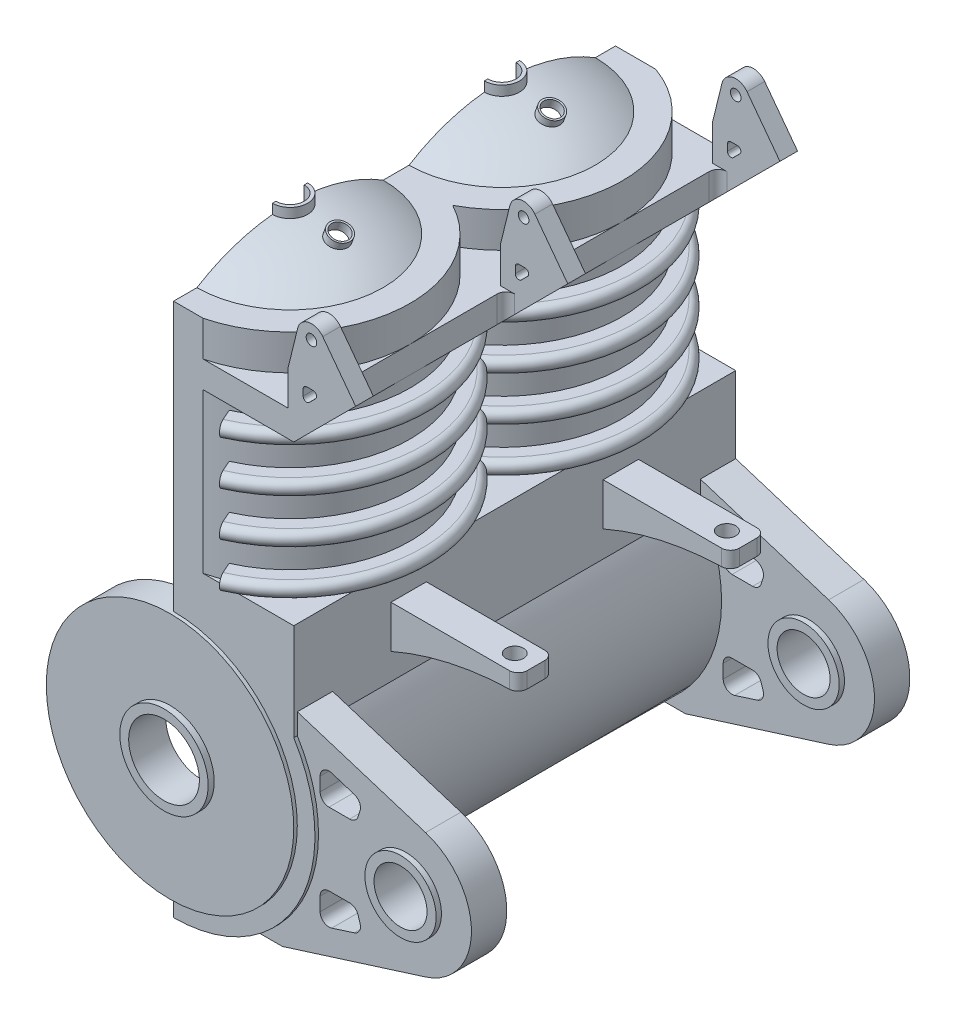
from build123d import *

# Parameters (mm, degrees)
BOSS_EXTRUDE1_DEPTH  = 25
SKETCH7_R            = 5
CUT_EXTRUDE1_DEPTH   = 20
SKETCH8_R            = 7
CUT_EXTRUDE2_DEPTH   = 39.525835487
CUT_EXTRUDE3_DEPTH   = 9
REVOLVE1_ANGLE       = 156
LPATTERN1_COUNT      = 2
LPATTERN1_PITCH      = 12
SKETCH13_R           = 5.038621202
CUT_EXTRUDE4_DEPTH   = 15
BOSS_EXTRUDE2_START  = -1
SKETCH14_R           = 7
SKETCH14_R_2         = 2.5
BOSS_EXTRUDE2_DEPTH  = 1.5
LPATTERN3_COUNT      = 3
LPATTERN3_PITCH      = 12
BOSS_EXTRUDE4_START  = 0.2
SKETCH15_R           = 7
BOSS_EXTRUDE4_DEPTH  = 0.2
BOSS_EXTRUDE5_START  = -1.6
SKETCH16_R           = 2.5
SKETCH16_R_2         = 2
BOSS_EXTRUDE5_DEPTH  = 2.1
LPATTERN4_COUNT      = 3
LPATTERN4_PITCH      = 12.22
BOSS_EXTRUDE6_START  = 2
BOSS_EXTRUDE6_DEPTH  = 2
SKETCH22_R           = 2
CUT_EXTRUDE5_DEPTH   = 42.077109336
SKETCH23_R           = 2.015
BOSS_EXTRUDE7_DEPTH  = 2
LPATTERN5_COUNT      = 2
LPATTERN5_PITCH      = 22.8
BOSS_EXTRUDE8_START  = 0.3
SKETCH25_R           = 2.015
SKETCH25_R_2         = 1.5
BOSS_EXTRUDE8_DEPTH  = 2.6
LPATTERN6_COUNT      = 2
LPATTERN6_PITCH      = 22.8
CUT_EXTRUDE6_DEPTH   = 43.954277827
REVOLVE3_ANGLE       = 180
LPATTERN7_COUNT      = 2
LPATTERN7_PITCH      = 12
SKETCH32_R           = 0.995
CUT_EXTRUDE7_DEPTH   = 10.3
BOSS_EXTRUDE9_START  = 1.2
BOSS_EXTRUDE9_DEPTH  = 0.8
SKETCH35_R           = 0.6
CUT_EXTRUDE8_DEPTH   = 10.8
SKETCH36_R           = 0.3
BOSS_EXTRUDE10_DEPTH = 1
LPATTERN8_COUNT      = 3
LPATTERN8_PITCH      = 12
FILLET2_R            = 0.5
BOSS_EXTRUDE11_START = -5.5
BOSS_EXTRUDE11_DEPTH = 2
LPATTERN9_COUNT      = 2
LPATTERN9_PITCH      = 12
SKETCH38_R           = 0.5
CUT_EXTRUDE9_DEPTH   = 2
FILLET4_R            = 0.5
SKETCH39_W           = 5.995424261
SKETCH39_H           = 2.838070656
CUT_EXTRUDE10_DEPTH  = 45.38321737
SKETCH40_R           = 0.3
BOSS_EXTRUDE12_DEPTH = 1
LPATTERN10_COUNT     = 3
LPATTERN10_PITCH     = 12
EXTRUDE_THIN1_START  = 1.9
SKETCH35_2_R         = 0.6
SKETCH35_2_R_2       = 0.5
EXTRUDE_THIN1_DEPTH  = 0.5


with BuildPart() as part:
    # Sketch2 → Boss-Extrude1 (new body)
    with BuildSketch(Plane.XY):
        with BuildLine():
            Line((0, 28.2), (0, 0))
            ThreePointArc((0, 0), (6.989781542, 4.108605135), (6.8, 12.214261501))
            Line((6.8, 12.214261501), (6.8, 28.2))
            Line((6.8, 28.2), (0, 28.2))
        make_face()
    extrude(amount=BOSS_EXTRUDE1_DEPTH)

    # Sketch7 → Cut-Extrude1 (cut)
    with BuildSketch(Plane(origin=(0, 28.2, 0), x_dir=(1, 0, 0), z_dir=(0, 1, 0))):
        with Locations((0, -6.41)):
            Circle(SKETCH7_R)
        with Locations((0, -18.41)):
            Circle(SKETCH7_R)
    extrude(amount=-CUT_EXTRUDE1_DEPTH, mode=Mode.SUBTRACT)

    # Sketch8 → Cut-Extrude2 (cut, through all)
    with BuildSketch(Plane.XY.offset(25)):
        with Locations((0, 8)):
            Circle(SKETCH8_R)
    extrude(amount=-CUT_EXTRUDE2_DEPTH, mode=Mode.SUBTRACT)

    # Sketch10 → Cut-Extrude3 (cut)
    with BuildSketch(Plane(origin=(0, 26.7, 0), x_dir=(1, 0, 0), z_dir=(0, 1, 0))):
        with BuildLine():
            Line((0, 0.39), (7.457375811, 0.39))
            Line((7.457375811, 0.39), (7.457375811, -25.21))
            Line((7.457375811, -25.21), (0, -25.21))
            ThreePointArc((0, -25.21), (6.596969001, -20.05924225), (3.2, -12.41))
            ThreePointArc((3.2, -12.41), (6.596969001, -4.76075775), (0, 0.39))
        make_face()
    extrude(amount=-CUT_EXTRUDE3_DEPTH, mode=Mode.SUBTRACT)

    # Sketch12 → Revolve1 (revolve)
    with BuildSketch(Plane.ZY):
        with BuildLine():
            Line((0.68, 17.35), (0.68, 27.35))
            Line((0.68, 27.35), (0.175, 27.35))
            Line((0.175, 27.35), (0.175, 26.05))
            Line((0.175, 26.05), (-1.07, 26.05))
            ThreePointArc((-1.07, 26.05), (-1.47, 25.65), (-1.07, 25.25))
            Line((-1.07, 25.25), (0.175, 25.25))
            Line((0.175, 25.25), (0.175, 23.55))
            Line((0.175, 23.55), (-1.07, 23.55))
            ThreePointArc((-1.07, 23.55), (-1.47, 23.15), (-1.07, 22.75))
            Line((-1.07, 22.75), (0.175, 22.75))
            Line((0.175, 22.75), (0.175, 21.05))
            Line((0.175, 21.05), (-1.07, 21.05))
            ThreePointArc((-1.07, 21.05), (-1.47, 20.65), (-1.07, 20.25))
            Line((-1.07, 20.25), (0.175, 20.25))
            Line((0.175, 20.25), (0.175, 18.55))
            Line((0.175, 18.55), (-1.07, 18.55))
            ThreePointArc((-1.07, 18.55), (-1.47, 18.15), (-1.07, 17.75))
            Line((-1.07, 17.75), (0.175, 17.75))
            Line((0.175, 17.75), (0.175, 17.35))
            Line((0.175, 17.35), (0.68, 17.35))
        make_face()
    revolve1 = revolve(axis=Axis((0, 28.2, 6.41), (0, -1, 0)), revolution_arc=REVOLVE1_ANGLE)

    # LPattern1: Revolve1 ×2
    with Locations(*[(0, 0, i * LPATTERN1_PITCH) for i in range(1, LPATTERN1_COUNT)]):
        add(revolve1)

    # Sketch13 → Cut-Extrude4 (cut)
    with BuildSketch(Plane(origin=(0, 28.2, 0), x_dir=(1, 0, 0), z_dir=(0, 1, 0))):
        with Locations((0, -6.41)):
            Circle(SKETCH13_R)
    extrude(amount=-CUT_EXTRUDE4_DEPTH, mode=Mode.SUBTRACT)

    # Sketch14 → Boss-Extrude2 (add)
    with BuildSketch(Plane(origin=(0, 0, 0), x_dir=(-1, 0, 0), z_dir=(0, 0, -1)).offset(BOSS_EXTRUDE2_START)):
        with Locations((0, 8)):
            Circle(SKETCH14_R)
        with Locations((0, 8)):
            Circle(SKETCH14_R_2, mode=Mode.SUBTRACT)
    boss_extrude2 = extrude(amount=BOSS_EXTRUDE2_DEPTH)

    # LPattern3: Boss-Extrude2 ×3
    with Locations(*[(0, 0, i * LPATTERN3_PITCH) for i in range(1, LPATTERN3_COUNT)]):
        add(boss_extrude2)

    # Sketch15 → Boss-Extrude4 (add)
    with BuildSketch(Plane.XY.offset(25).offset(BOSS_EXTRUDE4_START)):
        with Locations((0, 8)):
            Circle(SKETCH15_R)
    extrude(amount=-BOSS_EXTRUDE4_DEPTH)

    # Sketch16 → Boss-Extrude5 (add)
    with BuildSketch(Plane(origin=(0, 0, -0.5), x_dir=(-1, 0, 0), z_dir=(0, 0, -1)).offset(BOSS_EXTRUDE5_START)):
        with Locations((0, 8)):
            Circle(SKETCH16_R)
        with Locations((0, 8)):
            Circle(SKETCH16_R_2, mode=Mode.SUBTRACT)
    boss_extrude5 = extrude(amount=BOSS_EXTRUDE5_DEPTH)

    # LPattern4: Boss-Extrude5 ×3
    with Locations(*[(0, 0, i * LPATTERN4_PITCH) for i in range(1, LPATTERN4_COUNT)]):
        add(boss_extrude5)

    # Sketch18 → Boss-Extrude6 (add)
    with BuildSketch(Plane(origin=(0, 28.2, 0), x_dir=(1, 0, 0), z_dir=(0, 1, 0)).offset(BOSS_EXTRUDE6_START)):
        with BuildLine():
            Line((0, -13.41), (0, -11.448621202))
            ThreePointArc((0, -11.448621202), (5.038621202, -6.41), (0, -1.371378798))
            Line((0, -1.371378798), (0, 0))
            Line((0, 0), (2.269779725, 0))
            ThreePointArc((2.269779725, 0), (5.553129844, -2.485366395), (6.8, -6.41))
            ThreePointArc((6.8, -6.41), (5.830951895, -9.908571137), (3.2, -12.41))
            ThreePointArc((3.2, -12.41), (5.830951895, -14.911428863), (6.8, -18.41))
            ThreePointArc((6.8, -18.41), (5.368553353, -22.583563813), (1.676872088, -25))
            Line((1.676872088, -25), (0, -25))
            Line((0, -25), (0, -23.41))
            ThreePointArc((0, -23.41), (5, -18.41), (0, -13.41))
        make_face()
    extrude(amount=-BOSS_EXTRUDE6_DEPTH)

    # Sketch22 → Cut-Extrude5 (cut, through all)
    with BuildSketch(Plane.XY.offset(25.2)):
        with Locations((0, 8)):
            Circle(SKETCH22_R)
    extrude(amount=-CUT_EXTRUDE5_DEPTH, mode=Mode.SUBTRACT)

    # Sketch23 → Boss-Extrude7 (add)
    with BuildSketch(Plane(origin=(0, 0, 0), x_dir=(-1, 0, 0), z_dir=(0, 0, -1))):
        with BuildLine():
            Line((-6.8, 12.214261501), (-6.8, 13.383477618))
            Line((-6.8, 13.383477618), (-14.055618516, 11.095789887))
            ThreePointArc((-14.055618516, 11.095789887), (-16.65, 7.5575), (-14.055618516, 4.019210113))
            Line((-14.055618516, 4.019210113), (-5.953921411, 1.464754828))
            Line((-5.953921411, 1.464754828), (-4.614170623, 1.464754828))
            ThreePointArc((-4.614170623, 1.464754828), (-7.839566071, 6.405884629), (-6.8, 12.214261501))
        make_face()
        with Locations((-12.94, 7.5575)):
            Circle(SKETCH23_R, mode=Mode.SUBTRACT)
    boss_extrude7 = extrude(amount=-BOSS_EXTRUDE7_DEPTH)

    # LPattern5: Boss-Extrude7 ×2
    with Locations(*[(0, 0, i * LPATTERN5_PITCH) for i in range(1, LPATTERN5_COUNT)]):
        add(boss_extrude7)

    # Sketch25 → Boss-Extrude8 (add)
    with BuildSketch(Plane(origin=(0, 0, 0), x_dir=(-1, 0, 0), z_dir=(0, 0, -1)).offset(BOSS_EXTRUDE8_START)):
        with Locations((-12.94, 7.5575)):
            Circle(SKETCH25_R)
        with Locations((-12.94, 7.5575)):
            Circle(SKETCH25_R_2, mode=Mode.SUBTRACT)
    boss_extrude8 = extrude(amount=-BOSS_EXTRUDE8_DEPTH)

    # LPattern6: Boss-Extrude8 ×2
    with Locations(*[(0, 0, i * LPATTERN6_PITCH) for i in range(1, LPATTERN6_COUNT)]):
        add(boss_extrude8)

    # Sketch26 → Cut-Extrude6 (cut, through all)
    with BuildSketch(Plane(origin=(0, 0, 0), x_dir=(-1, 0, 0), z_dir=(0, 0, -1))):
        with BuildLine():
            Line((-8.744066409, 11.357042557), (-10.026180371, 10.94772918))
            ThreePointArc((-10.026180371, 10.94772918), (-10.318448219, 10.700694538), (-10.350432926, 10.31935009))
            Line((-10.350432926, 10.31935009), (-10.23520794, 9.958424768))
            ThreePointArc((-10.23520794, 9.958424768), (-10.053822929, 9.706735862), (-9.758892118, 9.610488035))
            Line((-9.758892118, 9.610488035), (-8.592003142, 9.610488035))
            ThreePointArc((-8.592003142, 9.610488035), (-8.238449752, 9.756934644), (-8.092003142, 10.110488035))
            Line((-8.092003142, 10.110488035), (-8.092003142, 10.880726734))
            ThreePointArc((-8.092003142, 10.880726734), (-8.297072331, 11.284478907), (-8.744066409, 11.357042557))
        make_face()
        with BuildLine():
            Line((-8.092003142, 5.004511965), (-8.092003142, 4.234273266))
            ThreePointArc((-8.092003142, 4.234273266), (-8.297072331, 3.830521093), (-8.744066409, 3.757957443))
            Line((-8.744066409, 3.757957443), (-10.026180371, 4.16727082))
            ThreePointArc((-10.026180371, 4.16727082), (-10.318448219, 4.414305462), (-10.350432926, 4.79564991))
            Line((-10.350432926, 4.79564991), (-10.23520794, 5.156575232))
            ThreePointArc((-10.23520794, 5.156575232), (-10.053822929, 5.408264138), (-9.758892118, 5.504511965))
            Line((-9.758892118, 5.504511965), (-8.592003142, 5.504511965))
            ThreePointArc((-8.592003142, 5.504511965), (-8.238449752, 5.358065356), (-8.092003142, 5.004511965))
        make_face()
    extrude(amount=-CUT_EXTRUDE6_DEPTH, mode=Mode.SUBTRACT)

    # Sketch27 → Revolve3 (revolve)
    with BuildSketch(Plane.ZY):
        with BuildLine():
            Line((18.41, 31.7), (18.41, 31.58))
            ThreePointArc((18.41, 31.58), (15.799023171, 31.228756477), (13.373691828, 30.2))
            Line((13.373691828, 30.2), (13.142173124, 30.2))
            ThreePointArc((13.142173124, 30.2), (15.671387212, 31.317692031), (18.41, 31.7))
        make_face()
    revolve3 = revolve(axis=Axis((0, 30.2, 18.41), (0, -1, 0)), revolution_arc=REVOLVE3_ANGLE)

    # LPattern7: Revolve3 ×2
    with Locations(*[(0, 0, -i * LPATTERN7_PITCH) for i in range(1, LPATTERN7_COUNT)]):
        add(revolve3)

    # Sketch32 → Cut-Extrude7 (cut)
    with BuildSketch(Plane(origin=(0, 30.2, 0), x_dir=(1, 0, 0), z_dir=(0, 1, 0))):
        with Locations((0, -6.42377965)):
            Circle(SKETCH32_R)
        with Locations((0, -18.41)):
            Circle(SKETCH32_R)
    extrude(amount=CUT_EXTRUDE7_DEPTH, mode=Mode.SUBTRACT)

    # Sketch33 → Boss-Extrude9 (add)
    with BuildSketch(Plane(origin=(0, 30.2, 0), x_dir=(1, 0, 0), z_dir=(0, 1, 0)).offset(BOSS_EXTRUDE9_START)):
        with BuildLine():
            Line((0, -17.415), (0, -17.61))
            ThreePointArc((0, -17.61), (0.8, -18.41), (0, -19.21))
            Line((0, -19.21), (0, -19.405))
            ThreePointArc((0, -19.405), (0.995, -18.41), (0, -17.415))
        make_face()
        with BuildLine():
            Line((0, -5.42877965), (0, -5.62377965))
            ThreePointArc((0, -5.62377965), (0.8, -6.42377965), (0, -7.22377965))
            Line((0, -7.22377965), (0, -7.41877965))
            ThreePointArc((0, -7.41877965), (0.995, -6.42377965), (0, -5.42877965))
        make_face()
    extrude(amount=BOSS_EXTRUDE9_DEPTH)

    # Sketch35 → Cut-Extrude8 (cut)
    with BuildSketch(Plane(origin=(9.706092906, 26.667271091, 0), x_dir=(0, 0, 1), z_dir=(0.34202014332565694, 0.9396926207859128, -9.792001855813182e-15))):
        with Locations((6.41, -8.194002445)):
            Circle(SKETCH35_R)
        with Locations((18.41, -8.194002445)):
            Circle(SKETCH35_R)
    extrude(amount=CUT_EXTRUDE8_DEPTH, mode=Mode.SUBTRACT)

    # Sketch36 → Boss-Extrude10 (add)
    with BuildSketch(Plane(origin=(0, 0, 0), x_dir=(-1, 0, 0), z_dir=(0, 0, -1))):
        with BuildLine():
            Line((-10.655588583, 30.555588583), (-6.8, 26.7))
            Line((-6.8, 26.7), (-6.8, 28.2))
            Line((-6.8, 28.2), (-6.485, 28.2))
            Line((-6.485, 28.2), (-6.485, 30.2))
            Line((-6.485, 30.2), (-8.8, 30.2))
            Line((-8.8, 30.2), (-9.924299782, 31.324299782))
            ThreePointArc((-9.924299782, 31.324299782), (-10.684008383, 31.314824551), (-10.655588583, 30.555588583))
        make_face()
        with Locations((-10.299533188, 30.949066376)):
            Circle(SKETCH36_R, mode=Mode.SUBTRACT)
        with BuildLine():
            Line((-7.671064447, 29.071064447), (-8.030801073, 29.430801073))
            ThreePointArc((-8.030801073, 29.430801073), (-8.074155624, 29.648759116), (-7.889379717, 29.772222429))
            Line((-7.889379717, 29.772222429), (-7.529643091, 29.772222429))
            ThreePointArc((-7.529643091, 29.772222429), (-7.388221735, 29.713643786), (-7.329643091, 29.572222429))
            Line((-7.329643091, 29.572222429), (-7.329643091, 29.212485804))
            ThreePointArc((-7.329643091, 29.212485804), (-7.453106405, 29.027709897), (-7.671064447, 29.071064447))
        make_face(mode=Mode.SUBTRACT)
    boss_extrude10 = extrude(amount=-BOSS_EXTRUDE10_DEPTH)

    # LPattern8: Boss-Extrude10 ×3
    with Locations(*[(0, 0, i * LPATTERN8_PITCH) for i in range(1, LPATTERN8_COUNT)]):
        add(boss_extrude10)

    # Fillet2
    fillet2_edges = [part.edges().sort_by_distance(p)[0] for p in [
        (6.8, 27.45, 1),
        (6.8, 27.45, 24),
        (6.8, 27.45, 13),
        (6.8, 27.45, 12),
    ]]
    fillet(fillet2_edges, radius=FILLET2_R)

    # Sketch37 → Boss-Extrude11 (add)
    with BuildSketch(Plane(origin=(0, 0, 0), x_dir=(-1, 0, 0), z_dir=(0, 0, -1)).offset(BOSS_EXTRUDE11_START)):
        with BuildLine():
            Line((-6.8, 13.692703549), (-6.8, 16.1))
            Line((-6.8, 16.1), (-14, 16.1))
            Line((-14, 16.1), (-14, 15.2))
            ThreePointArc((-14, 15.2), (-10.321958993, 14.819135276), (-6.8, 13.692703549))
        make_face()
    boss_extrude11 = extrude(amount=-BOSS_EXTRUDE11_DEPTH)

    # LPattern9: Boss-Extrude11 ×2
    with Locations(*[(0, 0, i * LPATTERN9_PITCH) for i in range(1, LPATTERN9_COUNT)]):
        add(boss_extrude11)

    # Sketch38 → Cut-Extrude9 (cut)
    with BuildSketch(Plane(origin=(0, 16.1, 0), x_dir=(1, 0, 0), z_dir=(0, 1, 0))):
        with Locations((12.8, -6.5)):
            Circle(SKETCH38_R)
        with Locations((12.8, -18.5)):
            Circle(SKETCH38_R)
    extrude(amount=-CUT_EXTRUDE9_DEPTH, mode=Mode.SUBTRACT)

    # Fillet4
    fillet4_edges = [part.edges().sort_by_distance(p)[0] for p in [
        (14, 15.65, 5.5),
        (14, 15.65, 7.5),
        (14, 15.65, 17.5),
        (14, 15.65, 19.5),
    ]]
    fillet(fillet4_edges, radius=FILLET4_R)

    # Sketch39 → Cut-Extrude10 (cut, through all)
    with BuildSketch(Plane(origin=(0, 0, 0), x_dir=(-1, 0, 0), z_dir=(0, 0, -1))):
        with Locations((-10.282406693, 31.619035328)):
            Rectangle(SKETCH39_W, SKETCH39_H)
    extrude(amount=-CUT_EXTRUDE10_DEPTH, mode=Mode.SUBTRACT)

    # Sketch40 → Boss-Extrude12 (add)
    with BuildSketch(Plane(origin=(0, 0, 0), x_dir=(-1, 0, 0), z_dir=(0, 0, -1))):
        with BuildLine():
            Line((-10.3, 30.2), (-6.485, 30.2))
            Line((-6.485, 30.2), (-7.023090433, 32.39081804))
            ThreePointArc((-7.023090433, 32.39081804), (-7.640023099, 32.983841432), (-8.44, 32.68))
            Line((-8.44, 32.68), (-10.3, 30.2))
        make_face()
        with Locations((-7.8, 32.2)):
            Circle(SKETCH40_R, mode=Mode.SUBTRACT)
    boss_extrude12 = extrude(amount=-BOSS_EXTRUDE12_DEPTH)

    # LPattern10: Boss-Extrude12 ×3
    with Locations(*[(0, 0, i * LPATTERN10_PITCH) for i in range(1, LPATTERN10_COUNT)]):
        add(boss_extrude12)

    # Sketch35_2 → Extrude-Thin1 (add)
    # profile 1 of 2: a face of its own
    with BuildSketch(Plane(origin=(9.706092906, 26.667271091, 0), x_dir=(0, 0, 1), z_dir=(0.34202014332565694, 0.9396926207859128, -9.792001855813182e-15)).offset(EXTRUDE_THIN1_START)):
        with Locations((6.41, -8.194002445)):
            Circle(SKETCH35_2_R)
        with Locations((6.41, -8.194002445)):
            Circle(SKETCH35_2_R_2, mode=Mode.SUBTRACT)
    # profile 2 of 2: a face of its own
    with BuildSketch(Plane(origin=(9.706092906, 26.667271091, 0), x_dir=(0, 0, 1), z_dir=(0.34202014332565694, 0.9396926207859128, -9.792001855813182e-15)).offset(EXTRUDE_THIN1_START)):
        with Locations((18.41, -8.194002445)):
            Circle(SKETCH35_2_R)
        with Locations((18.41, -8.194002445)):
            Circle(SKETCH35_2_R_2, mode=Mode.SUBTRACT)
    extrude(amount=EXTRUDE_THIN1_DEPTH)


solid = part.part
